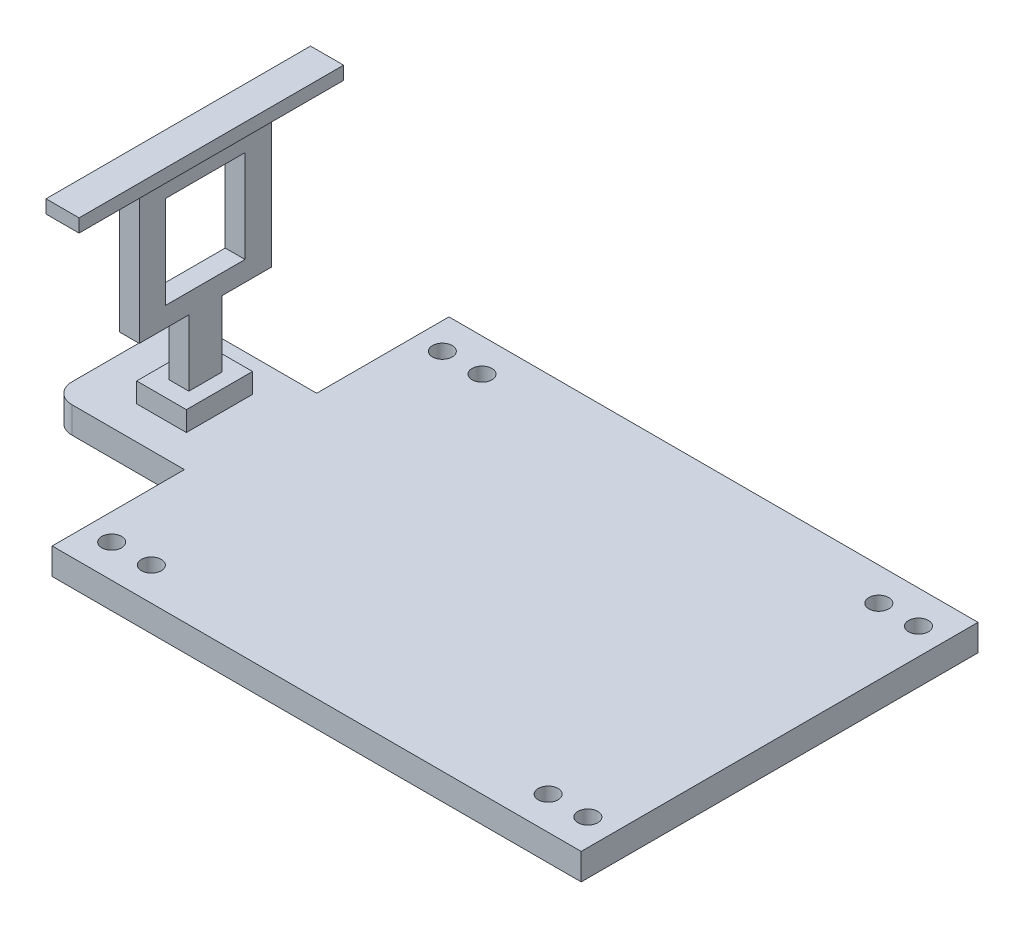
from build123d import *

# Parameters (mm, degrees)
SKETCH1_R           = 1.5
BOSS_EXTRUDE2_DEPTH = 4
SKETCH2_W           = 7.520049523
SKETCH2_H           = 10
BOSS_EXTRUDE3_DEPTH = 3
SKETCH4_W           = 12
SKETCH4_H           = 14
BOSS_EXTRUDE4_DEPTH = 64
CUT_EXTRUDE1_DEPTH  = 61
SKETCH6_W           = 5
SKETCH6_H           = 40
BOSS_EXTRUDE5_DEPTH = 2


with BuildPart() as part:
    # Sketch1 → Boss-Extrude2 (new body)
    with BuildSketch(Plane(origin=(0, 0, 0), x_dir=(1, 0, 0), z_dir=(0, 1, 0))):
        with BuildLine():
            Line((-54.068965517, 20), (-54.068965517, 40))
            Line((-54.068965517, 40), (25.931034483, 40))
            Line((25.931034483, 40), (25.931034483, -20))
            Line((25.931034483, -20), (-54.068965517, -20))
            Line((-54.068965517, -20), (-54.068965517, 0))
            Line((-54.068965517, 0), (-71.068965517, 0))
            ThreePointArc((-71.068965517, 0), (-73.190285861, 0.878679656), (-74.068965517, 3))
            Line((-74.068965517, 3), (-74.068965517, 17))
            ThreePointArc((-74.068965517, 17), (-73.190285861, 19.121320344), (-71.068965517, 20))
            Line((-71.068965517, 20), (-54.068965517, 20))
        make_face()
        with Locations((-50.068965517, 35)):
            Circle(SKETCH1_R, mode=Mode.SUBTRACT)
        with Locations((-44.068965517, 35)):
            Circle(SKETCH1_R, mode=Mode.SUBTRACT)
        with Locations((-50.068965517, -15)):
            Circle(SKETCH1_R, mode=Mode.SUBTRACT)
        with Locations((-44.068965517, -15)):
            Circle(SKETCH1_R, mode=Mode.SUBTRACT)
        with Locations((21.931034483, -15)):
            Circle(SKETCH1_R, mode=Mode.SUBTRACT)
        with Locations((15.931034483, -15)):
            Circle(SKETCH1_R, mode=Mode.SUBTRACT)
        with Locations((15.931034483, 35)):
            Circle(SKETCH1_R, mode=Mode.SUBTRACT)
        with Locations((21.931034483, 35)):
            Circle(SKETCH1_R, mode=Mode.SUBTRACT)
    extrude(amount=BOSS_EXTRUDE2_DEPTH)

    # Sketch2 → Boss-Extrude3 (add)
    with BuildSketch(Plane(origin=(0, 4, 0), x_dir=(1, 0, 0), z_dir=(0, 1, 0))):
        with Locations((-62.530885471, 10)):
            Rectangle(SKETCH2_W, SKETCH2_H)
    extrude(amount=BOSS_EXTRUDE3_DEPTH)

    # Sketch4 → Boss-Extrude4 (add)
    with BuildSketch(Plane(origin=(0, 0, 0), x_dir=(0, 0, -1), z_dir=(1, 0, 0))):
        Polygon((7.602984215, 7), (7.602984215, 17), (0.102984215, 17), (0.102984215, 37), (20.102984215, 37), (20.102984215, 17), (12.602984215, 17), (12.602984215, 7), align=None)
        with Locations((10.102984215, 27)):
            Rectangle(SKETCH4_W, SKETCH4_H, mode=Mode.SUBTRACT)
    extrude(amount=-BOSS_EXTRUDE4_DEPTH)

    # Sketch5 → Cut-Extrude1 (cut)
    with BuildSketch(Plane(origin=(0, 0, 0), x_dir=(0, 0, -1), z_dir=(1, 0, 0))):
        Polygon((0.102984215, 37), (0.102984215, 17), (7.602984215, 17), (7.602984215, 7), (12.602984215, 7), (12.602984215, 17), (20.102984215, 17), (20.102984215, 37), align=None)
    extrude(amount=-CUT_EXTRUDE1_DEPTH, mode=Mode.SUBTRACT)

    # Sketch6 → Boss-Extrude5 (add)
    with BuildSketch(Plane(origin=(0, 37, 0), x_dir=(1, 0, 0), z_dir=(0, 1, 0))):
        with Locations((-62.5, 10)):
            Rectangle(SKETCH6_W, SKETCH6_H)
    extrude(amount=BOSS_EXTRUDE5_DEPTH)


solid = part.part
